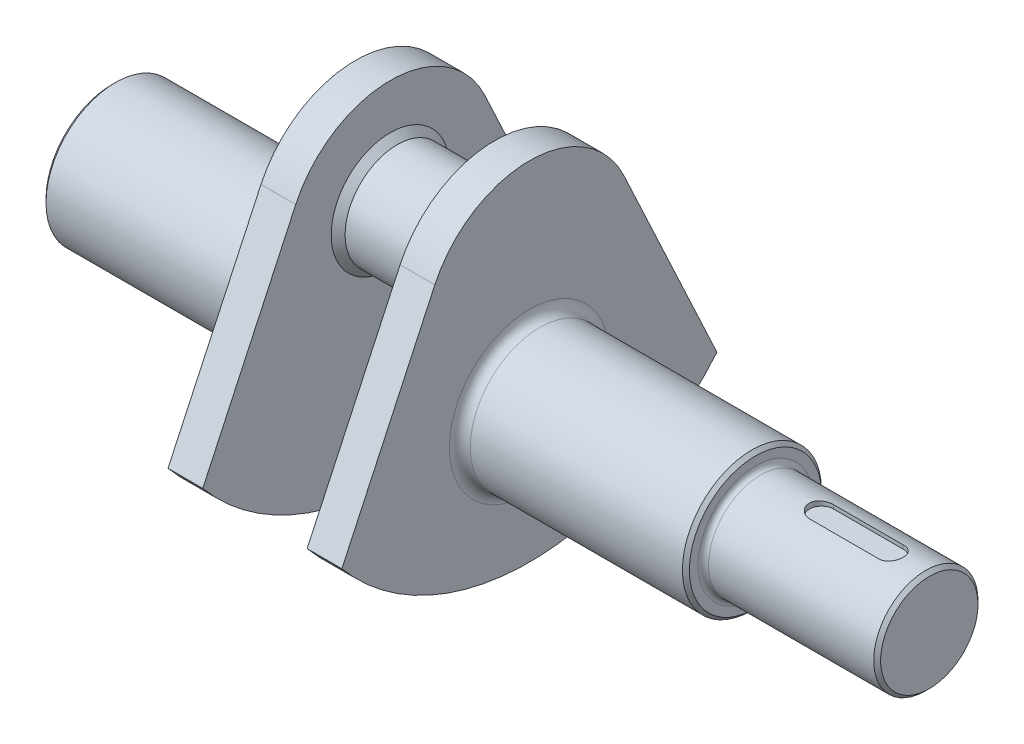
from build123d import *

# Parameters (mm, degrees)
IZIM2_R                     = 80
KES_EKSTR_ZYON1_DEPTH       = 10
IZIM3_R                     = 15
Y_KSEKLIK_EKSTR_ZYON1_DEPTH = 30
IZIM4_R                     = 80
KES_EKSTR_ZYON2_DEPTH       = 10
PAH1_SIZE                   = 2
IZIM5_R                     = 20
KES_EKSTR_ZYON3_DEPTH       = 5
IZIM6_R                     = 15
Y_KSEKLIK_EKSTR_ZYON2_DEPTH = 50
PAH2_SIZE                   = 1
RADYUS1_R                   = 1.5
PAH3_SIZE                   = 1
KES_EKSTR_ZYON4_DEPTH       = 1.5


with BuildPart() as part:
    # Çizim1 → Döndür2 (revolve)
    with BuildSketch(Plane.XY):
        with BuildLine():
            ThreePointArc((67, 20), (69.121320344, 20.878679656), (70, 23))
            Line((70, 23), (70, 80))
            Line((70, 80), (80, 80))
            Line((80, 80), (80, 0))
            Line((80, 0), (0, 0))
            Line((0, 0), (0, 19))
            Line((0, 19), (1, 20))
            Line((1, 20), (67, 20))
        make_face()
    d_nd_r2 = revolve(axis=Axis((0, 0, 0), (1, 0, 0)))

    # Çizim2 → Kes-Ekstrüzyon1 (cut)
    with BuildSketch(Plane.ZY.offset(-70)):
        Circle(IZIM2_R)
        with BuildLine():
            ThreePointArc((53.917959369, -14.641389511), (0, -40), (-53.917959369, -14.641389511))
            Line((-53.917959369, -14.641389511), (-27.189233611, 42.678547852))
            ThreePointArc((-27.189233611, 42.678547852), (0, 60), (27.189233611, 42.678547852))
            Line((27.189233611, 42.678547852), (53.917959369, -14.641389511))
        make_face(mode=Mode.SUBTRACT)
    extrude(amount=-KES_EKSTR_ZYON1_DEPTH, mode=Mode.SUBTRACT)

    # Çizim3 → Yükseklik-Ekstrüzyon1 (add)
    with BuildSketch(Plane(origin=(80, 0, 0), x_dir=(0, 0, -1), z_dir=(1, 0, 0))):
        with Locations((0, 30)):
            Circle(IZIM3_R)
    extrude(amount=Y_KSEKLIK_EKSTR_ZYON1_DEPTH)

    # Aynalama3: Döndür2 across plane
    add(d_nd_r2.mirror(Plane(origin=(95, 0, 0), x_dir=(0, 0, 1), z_dir=(1, 0, 0))))

    # Çizim4 → Kes-Ekstrüzyon2 (cut)
    with BuildSketch(Plane(origin=(120, 0, 0), x_dir=(0, 0, -1), z_dir=(1, 0, 0))):
        Circle(IZIM4_R)
        with BuildLine():
            ThreePointArc((53.917959369, -14.641389511), (0, -40), (-53.917959369, -14.641389511))
            Line((-53.917959369, -14.641389511), (-27.189233611, 42.678547852))
            ThreePointArc((-27.189233611, 42.678547852), (0, 60), (27.189233611, 42.678547852))
            Line((27.189233611, 42.678547852), (53.917959369, -14.641389511))
        make_face(mode=Mode.SUBTRACT)
    extrude(amount=-KES_EKSTR_ZYON2_DEPTH, mode=Mode.SUBTRACT)

    # Pah1
    pah1_edges = [part.edges().sort_by_distance(p)[0] for p in [
        (80, 30, 15),
        (110, 30, 15),
    ]]
    chamfer(pah1_edges, length=PAH1_SIZE)

    # Çizim5 → Kes-Ekstrüzyon3 (cut)
    with BuildSketch(Plane(origin=(190, 0, 0), x_dir=(0, 0, -1), z_dir=(1, 0, 0))):
        Circle(IZIM5_R)
    extrude(amount=-KES_EKSTR_ZYON3_DEPTH, mode=Mode.SUBTRACT)

    # Çizim6 → Yükseklik-Ekstrüzyon2 (add)
    with BuildSketch(Plane(origin=(185, 0, 0), x_dir=(0, 0, -1), z_dir=(1, 0, 0))):
        Circle(IZIM6_R)
    extrude(amount=Y_KSEKLIK_EKSTR_ZYON2_DEPTH)

    # Pah2
    pah2_edges = [part.edges().sort_by_distance(p)[0] for p in [
        (235, 0, 15),
    ]]
    chamfer(pah2_edges, length=PAH2_SIZE)

    # Radyus1
    radyus1_edges = [part.edges().sort_by_distance(p)[0] for p in [
        (185, 0, 15),
    ]]
    fillet(radyus1_edges, radius=RADYUS1_R)

    # Pah3
    pah3_edges = [part.edges().sort_by_distance(p)[0] for p in [
        (185, -20, 0),
    ]]
    chamfer(pah3_edges, length=PAH3_SIZE)

    # Çizim7 → Kes-Ekstrüzyon4 (cut)
    with BuildSketch(Plane(origin=(0, 15, 0), x_dir=(1, 0, 0), z_dir=(0, 1, 0))):
        with BuildLine():
            Line((224, -3.5), (204, -3.5))
            ThreePointArc((204, -3.5), (200.5, 0), (204, 3.5))
            Line((204, 3.5), (224, 3.5))
            ThreePointArc((224, 3.5), (227.5, 0), (224, -3.5))
        make_face()
    extrude(amount=-KES_EKSTR_ZYON4_DEPTH, mode=Mode.SUBTRACT)


solid = part.part
